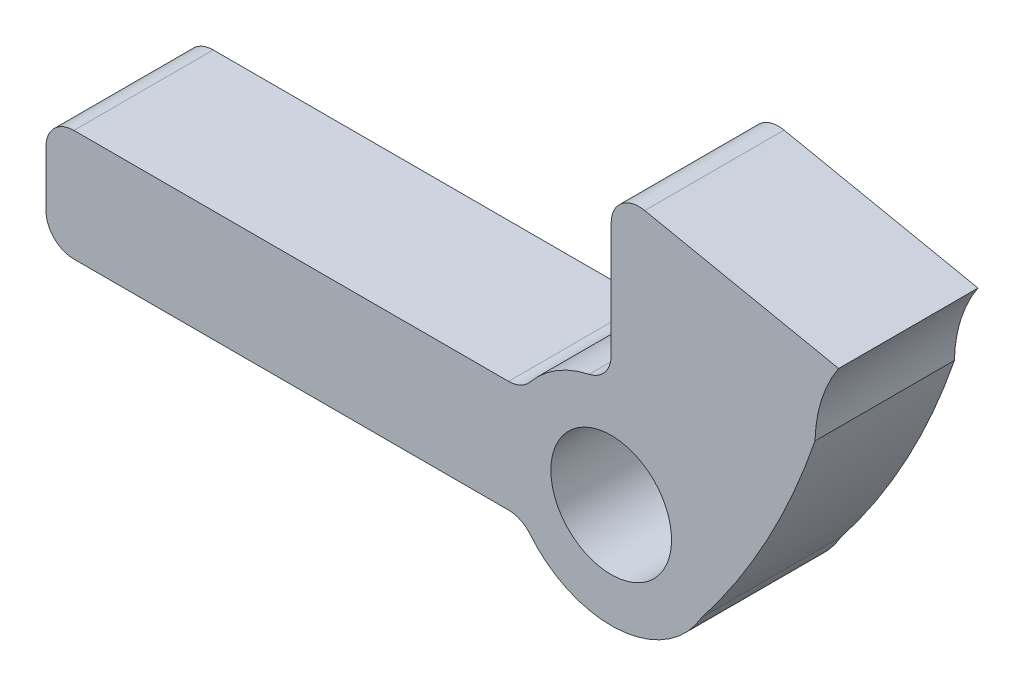
from build123d import *

# Parameters (mm, degrees)
SKETCH1_W           = 50
SKETCH1_H           = 50
BOSS_EXTRUDE1_DEPTH = 6.35
SKETCH2_OUTSIDE_W   = 66.2
SKETCH2_OUTSIDE_H   = 66.2
SKETCH2_OUTSIDE_R   = 2.75
CUT_EXTRUDE1_DEPTH  = 7.35


with BuildPart() as part:
    # Sketch1 → Boss-Extrude1 (new body)
    with BuildSketch(Plane.XY):
        with Locations((25, 25)):
            Rectangle(SKETCH1_W, SKETCH1_H)
    extrude(amount=BOSS_EXTRUDE1_DEPTH)

    # Sketch2 outside → Cut-Extrude1 (cut, through all)
    with BuildSketch(Plane(origin=(0, 0, 0), x_dir=(-1, 0, 0), z_dir=(0, 0, -1))):
        with Locations((-25, 25)):
            Rectangle(SKETCH2_OUTSIDE_W, SKETCH2_OUTSIDE_H)
        with BuildLine():
            Line((-26.850834583, 24.37770606), (-7.04230164, 24.37770606))
            ThreePointArc((-7.04230164, 24.37770606), (-6.144276028, 24.749680448), (-5.77230164, 25.64770606))
            Line((-5.77230164, 25.64770606), (-5.77230164, 28.18770606))
            ThreePointArc((-5.77230164, 28.18770606), (-6.144276028, 29.085731672), (-7.04230164, 29.45770606))
            Line((-7.04230164, 29.45770606), (-26.850834583, 29.45770606))
            ThreePointArc((-26.850834583, 29.45770606), (-27.395915456, 29.580628538), (-27.835480279, 29.925600797))
            ThreePointArc((-27.835480279, 29.925600797), (-29.039981102, 30.97869826), (-30.525270061, 31.573469818))
            ThreePointArc((-30.525270061, 31.573469818), (-31.245944628, 32.017090124), (-31.52790164, 32.81500682))
            Line((-31.52790164, 32.81500682), (-31.52790164, 38.057404626))
            ThreePointArc((-31.52790164, 38.057404626), (-31.996191822, 39.042372325), (-33.055714819, 39.300960963))
            Line((-33.055714819, 39.300960963), (-41.893380205, 37.485936348))
            ThreePointArc((-41.893380205, 37.485936348), (-41.111586239, 35.864517894), (-40.816192235, 34.08886534))
            ThreePointArc((-40.816192235, 34.08886534), (-38.634961437, 29.096054751), (-35.652347625, 24.53645606))
            ThreePointArc((-35.652347625, 24.53645606), (-31.908469933, 22.170435895), (-27.835480279, 23.909811323))
            ThreePointArc((-27.835480279, 23.909811323), (-27.395915456, 24.254783582), (-26.850834583, 24.37770606))
        make_face(mode=Mode.SUBTRACT)
        with Locations((-31.52790164, 26.91770606)):
            Circle(SKETCH2_OUTSIDE_R)
    extrude(amount=-CUT_EXTRUDE1_DEPTH, mode=Mode.SUBTRACT)


solid = part.part
